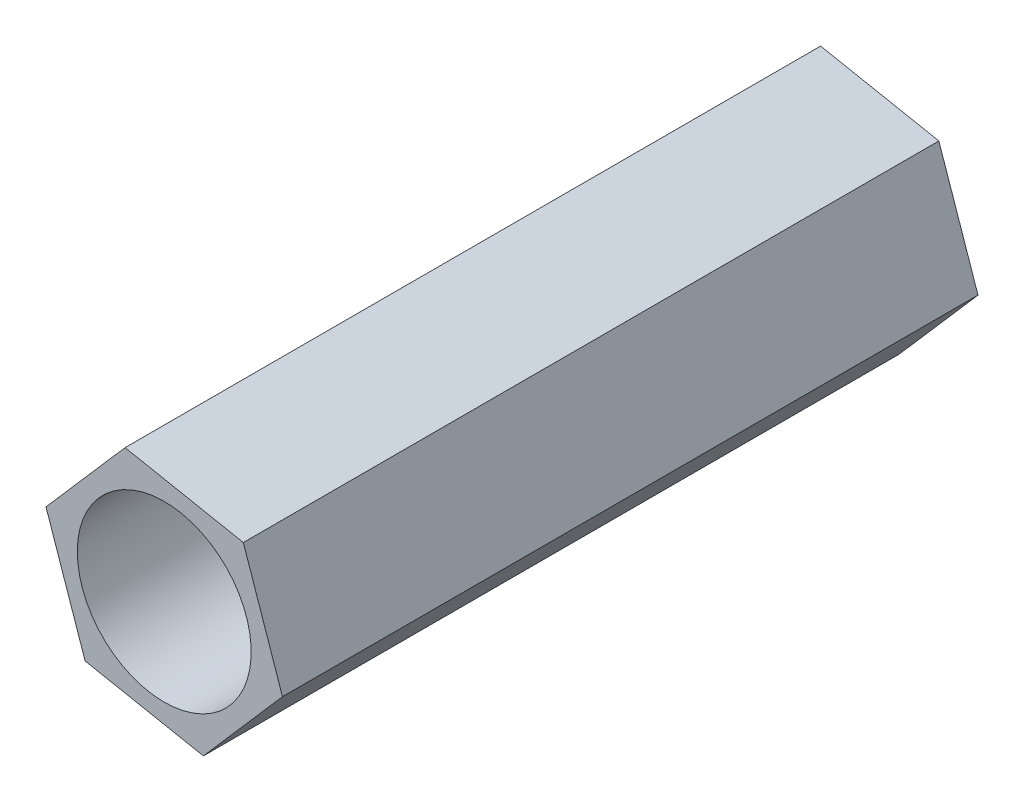
from build123d import *

# Parameters (mm, degrees)
EXTRUDE_1_DEPTH    = 10
HOLE_WIZARD_M3_1_D = 2.5


with BuildPart() as part:
    # 草图1 → 凸台-拉伸1 (new body)
    with BuildSketch(Plane.XY):
        Polygon((0.562771868, -1.638074426), (1.7, -0.331662479), (1.137228132, 1.306411947), (-0.562771868, 1.638074426), (-1.7, 0.331662479), (-1.137228132, -1.306411947), align=None)
    extrude(amount=-EXTRUDE_1_DEPTH)

    # M3 螺纹孔1 (through all)
    with Locations(Plane(origin=(0, 0, -10), x_dir=(-1, 0, 0), z_dir=(0, 0, -1))):
        with Locations((0, 0)):
            Hole(HOLE_WIZARD_M3_1_D / 2)


solid = part.part
